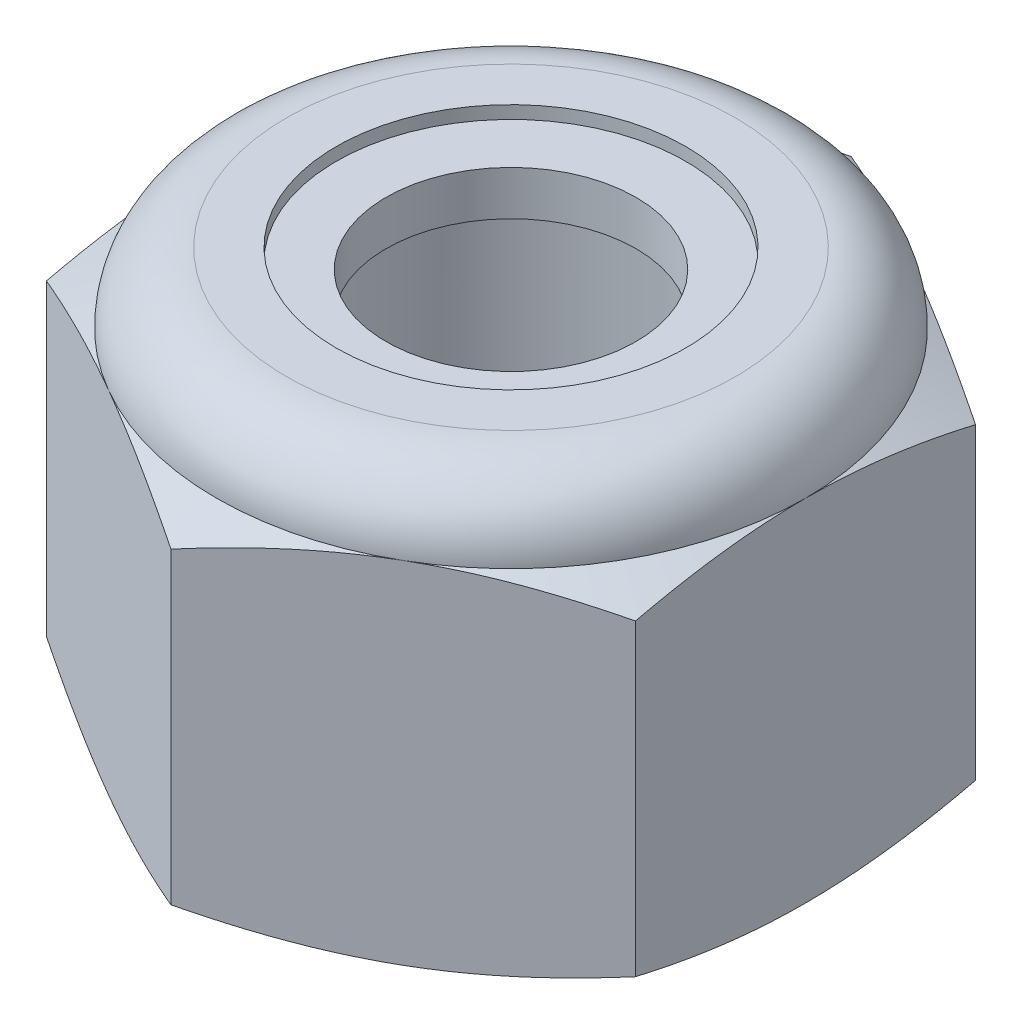
from build123d import *

# Parameters (mm, degrees)
SKETCH1_R      = 2
EXTRUDE1_DEPTH = 5
CHAMFER1_SIZE  = 0.2


with BuildPart() as part:
    # Sketch1 → Extrude1 (new body)
    with BuildSketch(Plane(origin=(0, 0, 0), x_dir=(1, 0, 0), z_dir=(0, 1, 0))):
        Polygon((0, 4.041451884), (-3.5, 2.020725942), (-3.5, -2.020725942), (0, -4.041451884), (3.5, -2.020725942), (3.5, 2.020725942), align=None)
        Circle(SKETCH1_R, mode=Mode.SUBTRACT)
    extrude(amount=EXTRUDE1_DEPTH)

    # Chamfer1
    chamfer1_edges = [part.edges().sort_by_distance(p)[0] for p in [
        (-2, 0, 0),
    ]]
    chamfer(chamfer1_edges, length=CHAMFER1_SIZE)

    # Sketch5 → Cut-Revolve3 (revolve, cut)
    with BuildSketch(Plane(origin=(0, 0, 0), x_dir=(0, 0, -1), z_dir=(1, 0, 0))):
        with BuildLine():
            Line((0, 0), (3.5, 0))
            Line((3.5, 0), (4.041451884, 0.25248316))
            Line((4.041451884, 0.25248316), (4.041451884, 3.914183506))
            Line((4.041451884, 3.914183506), (3.5, 4.166666667))
            ThreePointArc((3.5, 4.166666667), (3.255922318, 4.755922318), (2.666666667, 5))
            Line((2.666666667, 5), (2.666666667, 6.27))
            Line((2.666666667, 6.27), (5.311451884, 6.27))
            Line((5.311451884, 6.27), (5.311451884, -1.27))
            Line((5.311451884, -1.27), (0, -1.27))
            Line((0, -1.27), (0, 0))
        make_face()
    revolve(axis=Axis((0, 0, 0), (0, 1, 0)), mode=Mode.SUBTRACT)

    # Sketch6 → Cut-Revolve4 (revolve, cut)
    with BuildSketch(Plane(origin=(0, 0, 0), x_dir=(0, 0, -1), z_dir=(1, 0, 0))):
        with BuildLine():
            Line((0, 4.166666667), (3.3476, 4.166666667))
            ThreePointArc((3.3476, 4.166666667), (3.148159244, 4.648159244), (2.666666667, 4.8476))
            Line((2.666666667, 4.8476), (2.0762, 4.8476))
            Line((2.0762, 4.8476), (2.0762, 6.27))
            Line((2.0762, 6.27), (0, 6.27))
            Line((0, 6.27), (0, 4.166666667))
        make_face()
    revolve(axis=Axis((0, 6.27, 0), (0, -1, 0)), mode=Mode.SUBTRACT)


with BuildPart() as body_2:
    # Sketch7 → Revolve2 (revolve)
    with BuildSketch(Plane(origin=(0, 0, 0), x_dir=(0, 0, -1), z_dir=(1, 0, 0))):
        with BuildLine():
            Line((1.485733333, 4.242866667), (3.266579964, 4.242866667))
            ThreePointArc((3.266579964, 4.242866667), (3.066430175, 4.620419399), (2.666666667, 4.7714))
            Line((2.666666667, 4.7714), (1.485733333, 4.7714))
            Line((1.485733333, 4.7714), (1.485733333, 4.242866667))
        make_face()
    revolve(axis=Axis((0, 4.242866667, 0), (0, 1, 0)))


solid = Compound([part.part, body_2.part])
